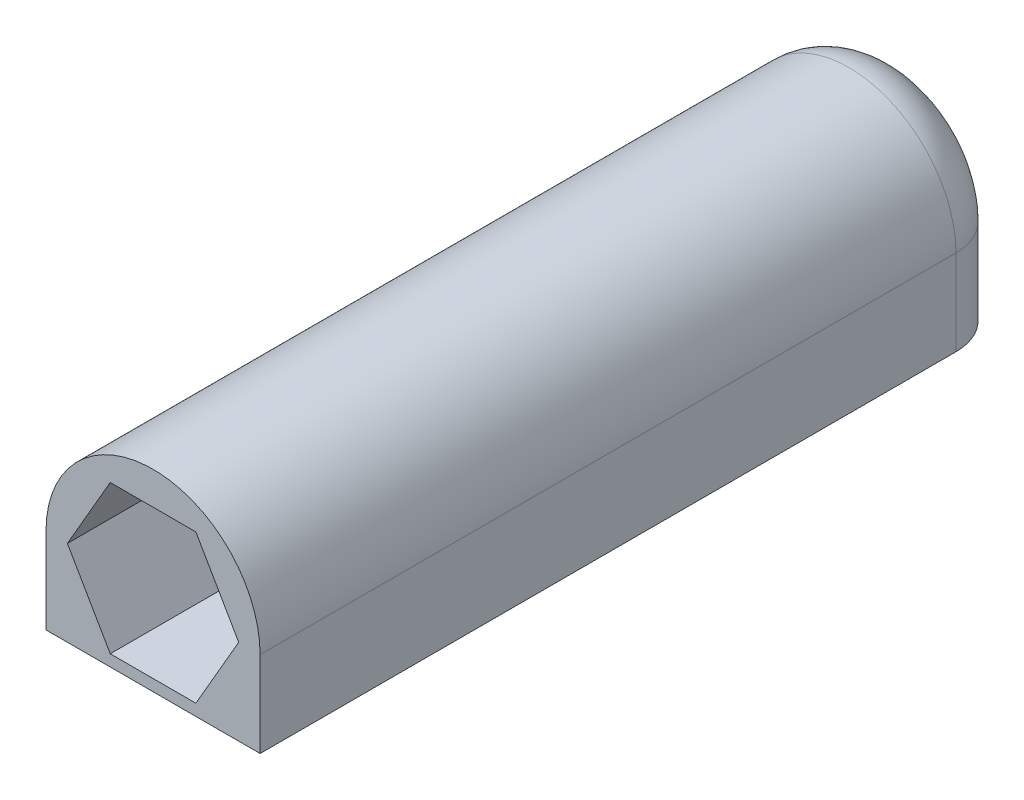
from build123d import *

# Parameters (mm, degrees)
BOSS_EXTRUDE1_DEPTH = 88.9
CUT_EXTRUDE1_DEPTH  = 30.48
CUT_EXTRUDE2_DEPTH  = 45.72
SKETCH5_R           = 2.794
CUT_EXTRUDE3_DEPTH  = 7.62
SWEEP1_PITCH        = 0.846666667
SWEEP1_HEIGHT       = 7.62
SWEEP1_RADIUS       = 3.175
SWEEP1_START_ANGLE  = 45
SKETCH8_W           = 3.119749742
SKETCH8_H           = 10.996256398
CUT_EXTRUDE4_DEPTH  = 12.7
FILLET1_R           = 6.35


with BuildPart() as part:
    # Sketch2 → Boss-Extrude1 (new body)
    with BuildSketch(Plane.XY):
        with BuildLine():
            Line((-12.7, 0), (-12.7, -10.16))
            Line((-12.7, -10.16), (12.7, -10.16))
            Line((12.7, -10.16), (12.7, 0))
            ThreePointArc((12.7, 0), (0, 12.7), (-12.7, 0))
        make_face()
    extrude(amount=-BOSS_EXTRUDE1_DEPTH)

    # Sketch3 → Cut-Extrude1 (cut)
    with BuildSketch(Plane.XY):
        Polygon((10.16, 0), (5.08, 8.798818102), (-5.08, 8.798818102), (-10.16, 0), (-5.08, -8.798818102), (5.08, -8.798818102), align=None)
    extrude(amount=-CUT_EXTRUDE1_DEPTH, mode=Mode.SUBTRACT)

    # Sketch4 → Cut-Extrude2 (cut)
    with BuildSketch(Plane.XY.offset(-30.48)):
        with BuildLine():
            Line((-10.16, 0), (-10.16, -10.16))
            Line((-10.16, -10.16), (-10.16, -11.566808787))
            Line((-10.16, -11.566808787), (10.16, -11.566808787))
            Line((10.16, -11.566808787), (10.16, -10.16))
            Line((10.16, -10.16), (10.16, 0))
            ThreePointArc((10.16, 0), (0, 10.16), (-10.16, 0))
        make_face()
    extrude(amount=-CUT_EXTRUDE2_DEPTH, mode=Mode.SUBTRACT)

    # Sketch5 → Cut-Extrude3 (cut)
    with BuildSketch(Plane(origin=(0, 0, -88.9), x_dir=(-1, 0, 0), z_dir=(0, 0, -1))):
        with Locations((0, 2.54)):
            Circle(SKETCH5_R)
    extrude(amount=-CUT_EXTRUDE3_DEPTH, mode=Mode.SUBTRACT)

    # Sweep1: sweep along a helix
    with BuildLine() as sweep1_path:
        add(Helix(SWEEP1_PITCH, SWEEP1_HEIGHT, SWEEP1_RADIUS, center=(0, 2.54, -88.9), direction=(0, 0, 1), mode=Mode.PRIVATE).rotate(Axis((0, 2.54, -88.9), (0, 0, 1)), SWEEP1_START_ANGLE))
    # Sketch7 → Sweep1 (sweep)
    with BuildSketch(Plane(origin=(2.24506403, 4.78506403, -81.28), x_dir=(0.029983551852803186, -0.029983551852795883, 0.9991005821420489), z_dir=(-0.7064707967201557, 0.7064707967199844, 0.04240314567834605))):
        Polygon((0.381, 0), (0, -0.635), (-0.381, 0), align=None)
    sweep(path=sweep1_path.line, is_frenet=True)

    # Sketch8 → Cut-Extrude4 (cut, symmetric)
    with BuildSketch(Plane(origin=(0, 0, 0), x_dir=(0, 0, -1), z_dir=(1, 0, 0))):
        with Locations((90.459874871, 3.5123312)):
            Rectangle(SKETCH8_W, SKETCH8_H)
    extrude(amount=CUT_EXTRUDE4_DEPTH, both=True, mode=Mode.SUBTRACT)

    # Fillet1
    fillet1_edges = [part.edges().sort_by_distance(p)[0] for p in [
        (12.7, -5.08, -88.9),
        (0, 12.7, -88.9),
        (-12.7, -5.08, -88.9),
    ]]
    fillet(fillet1_edges, radius=FILLET1_R)


solid = part.part
